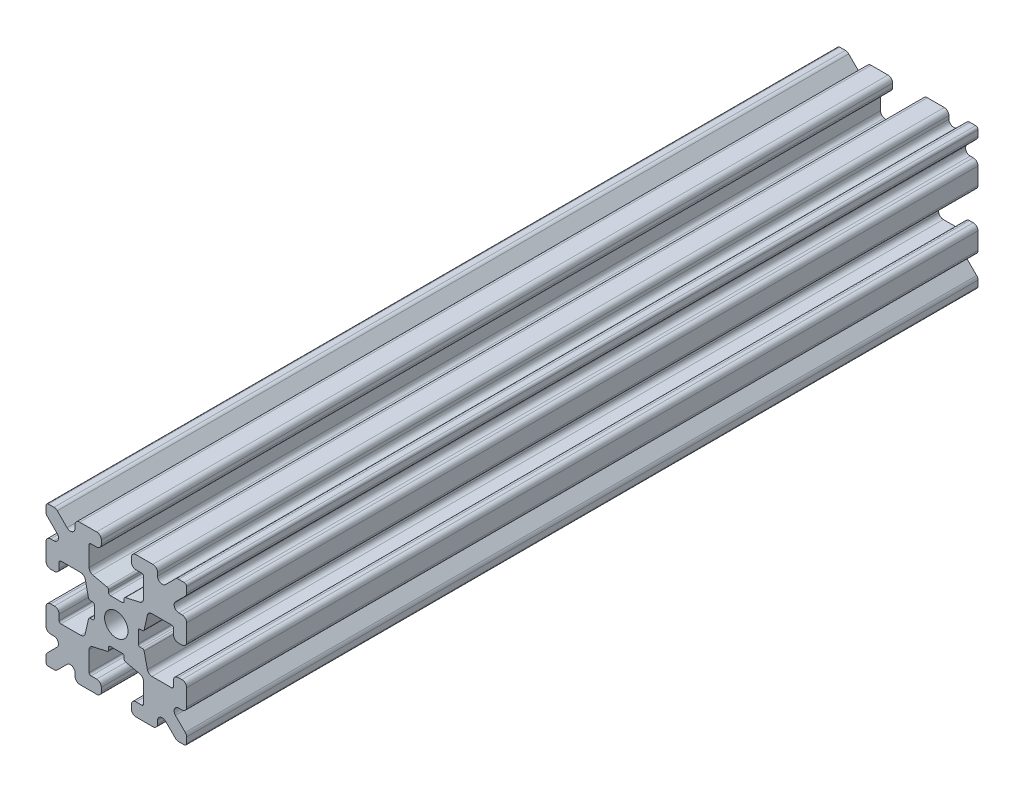
from build123d import *

# Parameters (mm, degrees)
SKETCH1_W           = 15
SKETCH1_H           = 15
SKETCH1_R           = 1.25
BOSS_EXTRUDE1_DEPTH = 42.21402
FILLET1_R           = 0.25
CUT_EXTRUDE1_DEPTH  = 85.42804
CUT_EXTRUDE3_DEPTH  = 85.42804
FILLET3_R           = 0.5
FILLET4_R           = 0.5
FILLET5_R           = 3
FILLET6_R           = 0.2
CUT_EXTRUDE4_DEPTH  = 85.42804
FILLET8_R           = 0.5
SKETCH6_W           = 5.1529354
SKETCH6_H           = 1.651
SKETCH6_W_2         = 1.651
SKETCH6_H_2         = 5.1529354
CUT_EXTRUDE5_DEPTH  = 85.42804
FILLET10_R          = 0.2


with BuildPart() as part:
    # Sketch1 → Boss-Extrude1 (new body, symmetric)
    with BuildSketch(Plane.XY):
        Rectangle(SKETCH1_W, SKETCH1_H)
        Circle(SKETCH1_R, mode=Mode.SUBTRACT)
    extrude(amount=BOSS_EXTRUDE1_DEPTH, both=True)

    # Fillet1
    fillet1_edges = [part.edges().sort_by_distance(p)[0] for p in [
        (7.5, -7.5, 0),
        (-7.5, -7.5, 0),
        (-7.5, 7.5, 0),
        (7.5, 7.5, 0),
    ]]
    fillet(fillet1_edges, radius=FILLET1_R)

    # Sketch2 → Cut-Extrude1 (cut, through all)
    with BuildSketch(Plane.XY.offset(42.21402)):
        Polygon((-7.5, 1.6), (-6.1, 1.6), (-6.1, 2.9), (-3.4, 2.9), (-3.4, -2.9), (-6.1, -2.9), (-6.1, -1.6), (-7.5, -1.6), align=None)
        Polygon((2.9, 6.1), (1.6, 6.1), (1.6, 7.5), (-1.6, 7.5), (-1.6, 6.1), (-2.9, 6.1), (-2.9, 3.4), (2.9, 3.4), align=None)
        Polygon((-1.6, -7.5), (-1.6, -6.1), (-2.9, -6.1), (-2.9, -3.4), (2.9, -3.4), (2.9, -6.1), (1.6, -6.1), (1.6, -7.5), align=None)
        Polygon((6.1, -2.9), (6.1, -1.6), (7.5, -1.6), (7.5, 1.6), (6.1, 1.6), (6.1, 2.9), (3.4, 2.9), (3.4, -2.9), align=None)
    extrude(amount=-CUT_EXTRUDE1_DEPTH, mode=Mode.SUBTRACT)

    # Sketch4 → Cut-Extrude3 (cut, through all)
    with BuildSketch(Plane.XY.offset(42.21402)):
        Polygon((-3.4, 2.9), (-2.75, 0), (-3.4, -2.9), align=None)
        Polygon((-2.9, 3.4), (0, 2.75), (2.9, 3.4), align=None)
        Polygon((3.4, 2.9), (2.75, 0), (3.4, -2.9), align=None)
        Polygon((-2.9, -3.4), (0, -2.75), (2.9, -3.4), align=None)
    extrude(amount=-CUT_EXTRUDE3_DEPTH, mode=Mode.SUBTRACT)

    # Fillet3
    fillet3_edges = [part.edges().sort_by_distance(p)[0] for p in [
        (1.6, -7.5, 0),
        (-1.6, -7.5, 0),
        (-1.6, -6.1, 0),
        (1.6, -6.1, 0),
        (6.1, 1.6, 0),
        (7.5, 1.6, 0),
        (7.5, -1.6, 0),
        (6.1, -1.6, 0),
        (-7.5, -1.6, 0),
        (-7.5, 1.6, 0),
        (-6.1, 1.6, 0),
        (-6.1, -1.6, 0),
        (-1.6, 6.1, 0),
        (-1.6, 7.5, 0),
        (1.6, 7.5, 0),
        (1.6, 6.1, 0),
    ]]
    fillet(fillet3_edges, radius=FILLET3_R)

    # Fillet4
    fillet4_edges = [part.edges().sort_by_distance(p)[0] for p in [
        (-2.9, -3.4, 0),
        (2.9, -3.4, 0),
        (3.4, -2.9, 0),
        (3.4, 2.9, 0),
        (-3.4, 2.9, 0),
        (-3.4, -2.9, 0),
        (2.9, 3.4, 0),
        (-2.9, 3.4, 0),
    ]]
    fillet(fillet4_edges, radius=FILLET4_R)

    # Fillet5
    fillet5_edges = [part.edges().sort_by_distance(p)[0] for p in [
        (-2.75, 0, 0),
        (0, 2.75, 0),
        (2.75, 0, 0),
        (0, -2.75, 0),
    ]]
    fillet(fillet5_edges, radius=FILLET5_R)

    # Fillet6
    fillet6_edges = [part.edges().sort_by_distance(p)[0] for p in [
        (-2.9, -6.1, 0),
        (2.9, -6.1, 0),
        (6.1, -2.9, 0),
        (6.1, 2.9, 0),
        (-6.1, 2.9, 0),
        (-6.1, -2.9, 0),
        (2.9, 6.1, 0),
        (-2.9, 6.1, 0),
    ]]
    fillet(fillet6_edges, radius=FILLET6_R)

    # Sketch5 → Cut-Extrude4 (cut, through all)
    with BuildSketch(Plane.XY.offset(42.21402)):
        Polygon((-7.5, 6.439339828), (-5.460660172, 4.4), (-7.5, 4.4), align=None)
        Polygon((-6.439339828, 7.5), (-4.4, 5.460660172), (-4.4, 7.5), align=None)
        Polygon((4.4, 7.5), (6.439339828, 7.5), (4.4, 5.460660172), align=None)
        Polygon((7.5, 6.439339828), (7.5, 4.4), (5.460660172, 4.4), align=None)
        Polygon((7.5, -6.439339828), (5.460660172, -4.4), (7.5, -4.4), align=None)
        Polygon((6.439339828, -7.5), (4.4, -5.460660172), (4.4, -7.5), align=None)
        Polygon((-4.4, -7.5), (-6.439339828, -7.5), (-4.4, -5.460660172), align=None)
        Polygon((-7.5, -6.439339828), (-7.5, -4.4), (-5.460660172, -4.4), align=None)
    extrude(amount=-CUT_EXTRUDE4_DEPTH, mode=Mode.SUBTRACT)

    # Fillet8
    fillet8_edges = [part.edges().sort_by_distance(p)[0] for p in [
        (-7.5, 4.4, 0),
        (-7.5, 6.439339828, 0),
        (-5.460660172, 4.4, 0),
        (7.5, -4.4, 0),
        (7.5, -6.439339828, 0),
        (5.460660172, -4.4, 0),
        (5.460660172, 4.4, 0),
        (7.5, 6.439339828, 0),
        (7.5, 4.4, 0),
        (-4.4, 7.5, 0),
        (-4.4, 5.460660172, 0),
        (-6.439339828, 7.5, 0),
        (-5.460660172, -4.4, 0),
        (-7.5, -6.439339828, 0),
        (-7.5, -4.4, 0),
        (4.4, 5.460660172, 0),
        (4.4, 7.5, 0),
        (6.439339828, 7.5, 0),
        (6.439339828, -7.5, 0),
        (4.4, -7.5, 0),
        (4.4, -5.460660172, 0),
        (-6.439339828, -7.5, 0),
        (-4.4, -5.460660172, 0),
        (-4.4, -7.5, 0),
    ]]
    fillet(fillet8_edges, radius=FILLET8_R)

    # Sketch6 → Cut-Extrude5 (cut, through all)
    with BuildSketch(Plane.XY.offset(42.21402)):
        with Locations((4.9235323, 0)):
            Rectangle(SKETCH6_W, SKETCH6_H)
        with Locations((0, -4.9235323)):
            Rectangle(SKETCH6_W_2, SKETCH6_H_2)
        with Locations((-4.9235323, 0)):
            Rectangle(SKETCH6_W, SKETCH6_H)
        with Locations((0, 4.9235323)):
            Rectangle(SKETCH6_W_2, SKETCH6_H_2)
    extrude(amount=-CUT_EXTRUDE5_DEPTH, mode=Mode.SUBTRACT)

    # Fillet10
    fillet10_edges = [part.edges().sort_by_distance(p)[0] for p in [
        (0.8255, -2.935025862, 0),
        (-0.8255, -2.935025862, 0),
        (0.8255, -2.3470646, 0),
        (-0.8255, -2.3470646, 0),
        (2.935025862, 0.8255, 0),
        (2.935025862, -0.8255, 0),
        (2.3470646, 0.8255, 0),
        (2.3470646, -0.8255, 0),
        (-2.935025862, -0.8255, 0),
        (-2.935025862, 0.8255, 0),
        (-2.3470646, -0.8255, 0),
        (-2.3470646, 0.8255, 0),
        (-0.8255, 2.935025862, 0),
        (0.8255, 2.935025862, 0),
        (-0.8255, 2.3470646, 0),
        (0.8255, 2.3470646, 0),
    ]]
    fillet(fillet10_edges, radius=FILLET10_R)


solid = part.part
